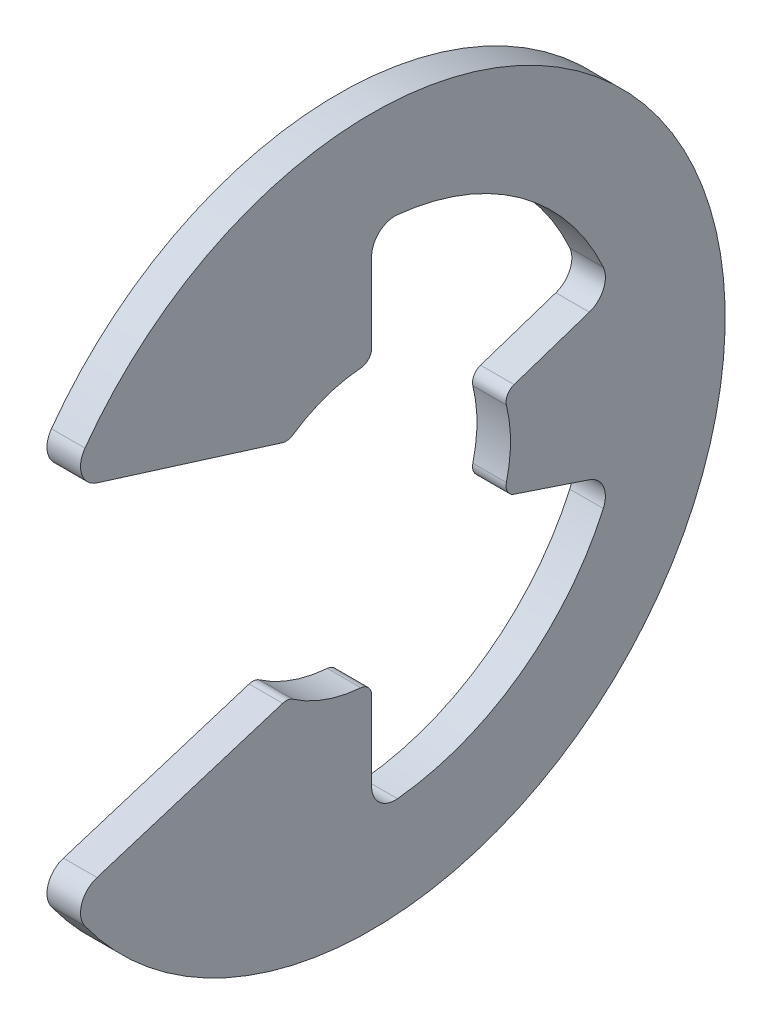
from build123d import *

# Parameters (mm, degrees)
BOSS_EXTRUDE1_DEPTH      = 0.3175
BOSS_EXTRUDE1_DEPTH_BACK = 0.3175
FILLET1_R                = 0.4445
FILLET2_R                = 0.22225


with BuildPart() as part:
    # Sketch3 → Boss-Extrude1 (new body, two sides)
    with BuildSketch(Plane(origin=(0, 0, 0), x_dir=(0, 0, -1), z_dir=(1, 0, 0))) as boss_extrude1_sk:
        with BuildLine():
            Line((2.493993522, -0.831331174), (4.564354048, -1.521451349))
            ThreePointArc((4.564354048, -1.521451349), (2.8131883, -3.903090272), (0, -4.811251613))
            Line((0, -4.811251613), (0, -2.6289))
            ThreePointArc((0, -2.6289), (-0.831331174, -2.493993522), (-1.57734, -2.10312))
            Line((-1.57734, -2.10312), (-5.759367109, -3.409486899))
            ThreePointArc((-5.759367109, -3.409486899), (6.6929, 0), (-5.759367109, 3.409486899))
            Line((-5.759367109, 3.409486899), (-1.57734, 2.10312))
            ThreePointArc((-1.57734, 2.10312), (-0.831331174, 2.493993522), (0, 2.6289))
            Line((0, 2.6289), (0, 4.811251613))
            ThreePointArc((0, 4.811251613), (2.8131883, 3.903090272), (4.564354048, 1.521451349))
            Line((4.564354048, 1.521451349), (2.493993522, 0.831331174))
            ThreePointArc((2.493993522, 0.831331174), (2.6289, 0), (2.493993522, -0.831331174))
        make_face()
    extrude(amount=BOSS_EXTRUDE1_DEPTH)
    extrude(boss_extrude1_sk.sketch, amount=-BOSS_EXTRUDE1_DEPTH_BACK)

    # Fillet1
    fillet1_edges = [part.edges().sort_by_distance(p)[0] for p in [
        (0, 1.521451349, -4.564354048),
        (0, 4.811251613, 0),
        (0, 3.409486899, 5.759367109),
        (0, -3.409486899, 5.759367109),
        (0, -4.811251613, 0),
        (0, -1.521451349, -4.564354048),
    ]]
    fillet(fillet1_edges, radius=FILLET1_R)

    # Fillet2
    fillet2_edges = [part.edges().sort_by_distance(p)[0] for p in [
        (0, 0.831331174, -2.493993522),
        (0, 2.6289, 0),
        (0, 2.10312, 1.57734),
        (0, -2.10312, 1.57734),
        (0, -2.6289, 0),
        (0, -0.831331174, -2.493993522),
    ]]
    fillet(fillet2_edges, radius=FILLET2_R)


solid = part.part
